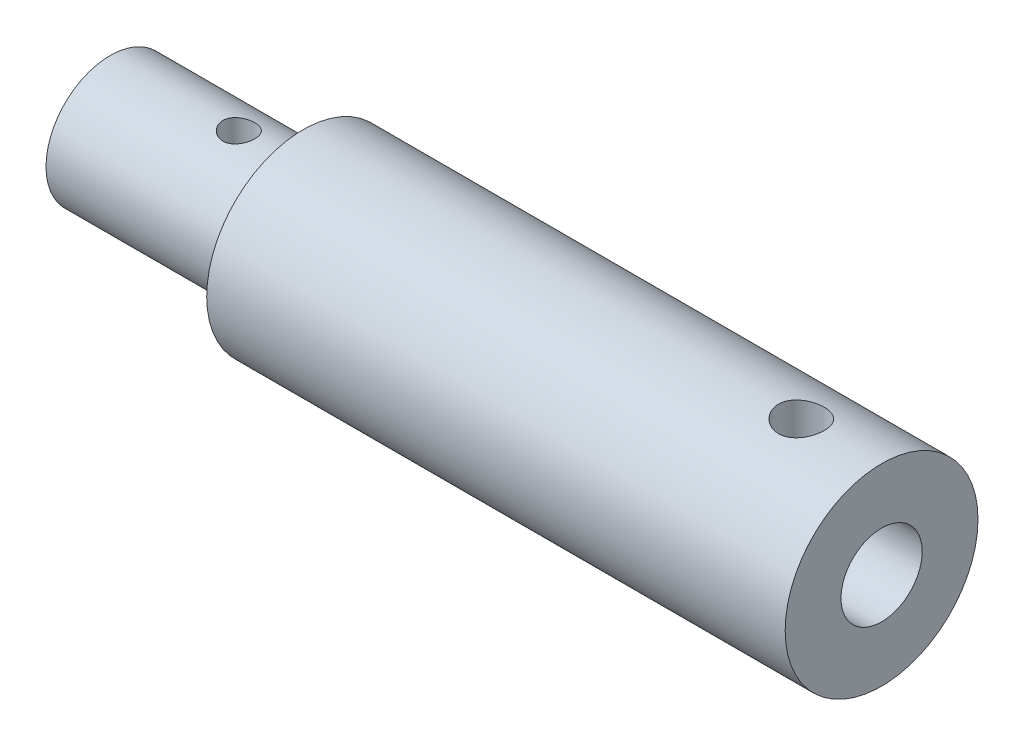
from build123d import *

# Parameters (mm, degrees)
SKETCH1_R               = 4.7625
BOSS_EXTRUDE1_DEPTH     = 38.1
SKETCH2_R               = 2.0066
CUT_EXTRUDE1_DEPTH      = 7.9248
SKETCH3_R               = 1.1303
CUT_EXTRUDE2_DEPTH      = 8.6868
SKETCH4_R               = 5.084796601
SKETCH4_R_2             = 3.175
CUT_EXTRUDE3_DEPTH      = 9.525
SKETCH5_R               = 0.7874
CUT_EXTRUDE4_DEPTH      = 5.762500124
CUT_EXTRUDE4_DEPTH_BACK = 5.7625001


with BuildPart() as part:
    # Sketch1 → Boss-Extrude1 (new body)
    with BuildSketch(Plane(origin=(0, 0, 0), x_dir=(0, 0, -1), z_dir=(1, 0, 0))):
        Circle(SKETCH1_R)
    extrude(amount=BOSS_EXTRUDE1_DEPTH)

    # Sketch2 → Cut-Extrude1 (cut)
    with BuildSketch(Plane(origin=(38.1, 0, 0), x_dir=(0, 0, -1), z_dir=(1, 0, 0))):
        Circle(SKETCH2_R)
    extrude(amount=-CUT_EXTRUDE1_DEPTH, mode=Mode.SUBTRACT)

    # Sketch3 → Cut-Extrude2 (cut)
    with BuildSketch(Plane(origin=(0, 0, 0), x_dir=(1, 0, 0), z_dir=(0, 1, 0))):
        with Locations((34.1376, 0)):
            Circle(SKETCH3_R)
    extrude(amount=CUT_EXTRUDE2_DEPTH, mode=Mode.SUBTRACT)

    # Sketch4 → Cut-Extrude3 (cut)
    with BuildSketch(Plane.ZY):
        Circle(SKETCH4_R)
        Circle(SKETCH4_R_2, mode=Mode.SUBTRACT)
    extrude(amount=-CUT_EXTRUDE3_DEPTH, mode=Mode.SUBTRACT)

    # Sketch5 → Cut-Extrude4 (cut, two sides)
    with BuildSketch(Plane(origin=(0, 0, 0), x_dir=(1, 0, 0), z_dir=(0, 1, 0))) as cut_extrude4_sk:
        with Locations((6.35, 0)):
            Circle(SKETCH5_R)
    extrude(amount=CUT_EXTRUDE4_DEPTH, mode=Mode.SUBTRACT)
    extrude(cut_extrude4_sk.sketch, amount=-CUT_EXTRUDE4_DEPTH_BACK, mode=Mode.SUBTRACT)


solid = part.part
